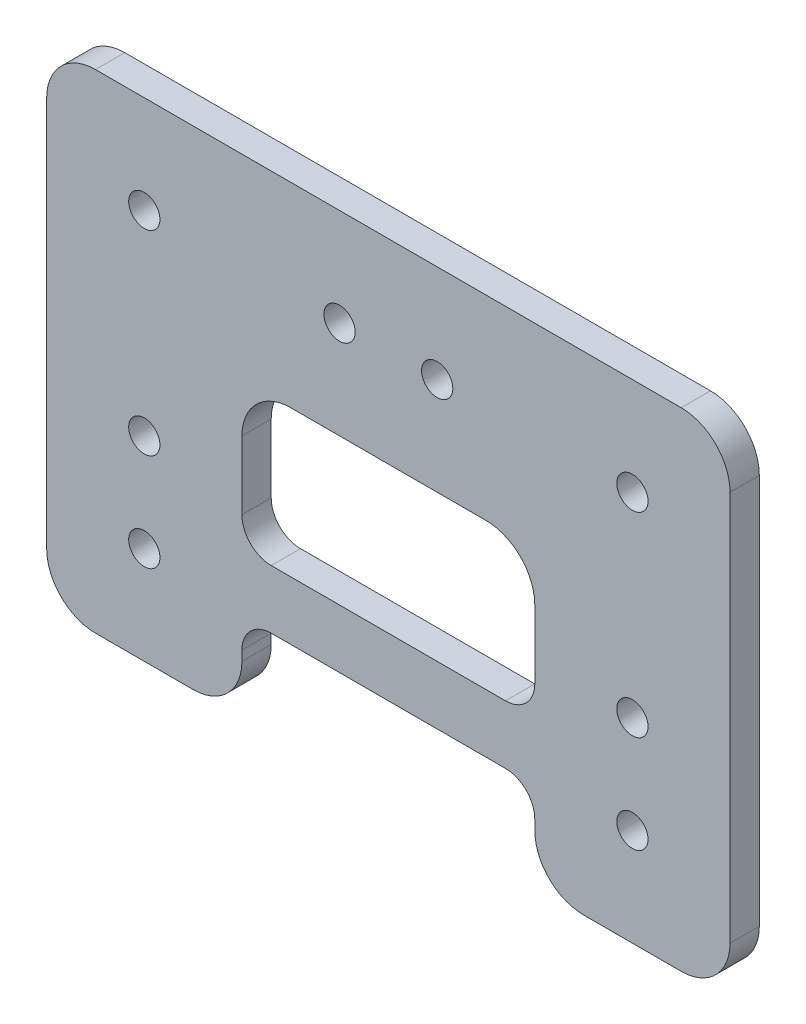
from build123d import *

# Parameters (mm, degrees)
SKETCH_1_W          = 70
SKETCH_1_H          = 50
SKETCH_1_R          = 1.6
EXTRUDE_1_DEPTH     = 3
SKETCH_2_W          = 30
SKETCH_2_H          = 30
CUT_EXTRUDE_1_DEPTH = 4
FILLET_1_R          = 5
SKETCH_3_W          = 30
SKETCH_3_H          = 6
EXTRUDE_2_DEPTH     = 3
FILLET_2_R          = 3


with BuildPart() as part:
    # 草图1 → 凸台-拉伸1 (new body)
    with BuildSketch(Plane.XY):
        Rectangle(SKETCH_1_W, SKETCH_1_H)
        with Locations((-25, -15)):
            Circle(SKETCH_1_R, mode=Mode.SUBTRACT)
        with Locations((-25, -5)):
            Circle(SKETCH_1_R, mode=Mode.SUBTRACT)
        with Locations((-25, 15)):
            Circle(SKETCH_1_R, mode=Mode.SUBTRACT)
        with Locations((-5, 15)):
            Circle(SKETCH_1_R, mode=Mode.SUBTRACT)
        with Locations((5, 15)):
            Circle(SKETCH_1_R, mode=Mode.SUBTRACT)
        with Locations((25, 15)):
            Circle(SKETCH_1_R, mode=Mode.SUBTRACT)
        with Locations((25, -5)):
            Circle(SKETCH_1_R, mode=Mode.SUBTRACT)
        with Locations((25, -15)):
            Circle(SKETCH_1_R, mode=Mode.SUBTRACT)
    extrude(amount=EXTRUDE_1_DEPTH)

    # 草图2 → 切除-拉伸1 (cut, through all)
    with BuildSketch(Plane.XY.offset(3)):
        with Locations((0, -10)):
            Rectangle(SKETCH_2_W, SKETCH_2_H)
    extrude(amount=-CUT_EXTRUDE_1_DEPTH, mode=Mode.SUBTRACT)

    # 圆角1
    fillet_1_edges = [part.edges().sort_by_distance(p)[0] for p in [
        (15, -25, 1.5),
        (-15, -25, 1.5),
        (-15, 5, 1.5),
        (15, 5, 1.5),
        (35, -25, 1.5),
        (-35, -25, 1.5),
        (-35, 25, 1.5),
        (35, 25, 1.5),
    ]]
    fillet(fillet_1_edges, radius=FILLET_1_R)

    # 草图3 → 凸台-拉伸2 (add)
    with BuildSketch(Plane.XY.offset(3)):
        with Locations((0, -13)):
            Rectangle(SKETCH_3_W, SKETCH_3_H)
    extrude(amount=-EXTRUDE_2_DEPTH)

    # 圆角2
    fillet_2_edges = [part.edges().sort_by_distance(p)[0] for p in [
        (-15, -16, 1.5),
        (-15, -10, 1.5),
        (15, -10, 1.5),
        (15, -16, 1.5),
    ]]
    fillet(fillet_2_edges, radius=FILLET_2_R)


solid = part.part
